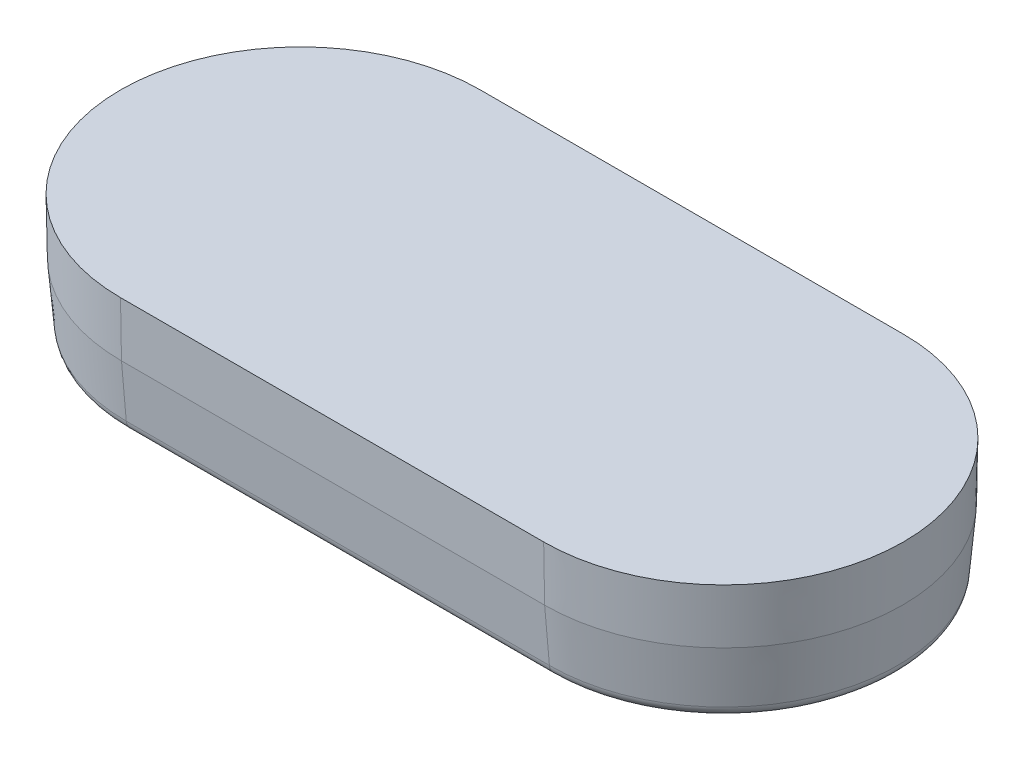
from build123d import *

# Parameters (mm, degrees)
BOSS_EXTRUDE1_DEPTH  = 6.35
BOSS_EXTRUDE1_DRAFT  = -1
CUT_EXTRUDE3_DEPTH   = 24.502539844
LPATTERN1_COUNT      = 12
LPATTERN1_PITCH      = 3.175
LPATTERN1_COUNT_DIR2 = 8
LPATTERN1_PITCH_DIR2 = 3.175
BOSS_EXTRUDE3_DEPTH  = 6.35
BOSS_EXTRUDE3_DRAFT  = -1
SKETCH8_OUTSIDE_W    = 56.55
SKETCH8_OUTSIDE_H    = 34.326
CUT_EXTRUDE4_DEPTH   = 24.502539844
CUT_EXTRUDE4_DRAFT   = 5
DRAFT2_ANGLE         = -5
FILLET2_R            = 0.635


with BuildPart() as part:
    # Sketch1 → Boss-Extrude1 (with draft: the straight prism first)
    with BuildSketch(Plane(origin=(0, 0, 0), x_dir=(1, 0, 0), z_dir=(0, 1, 0))):
        with BuildLine():
            ThreePointArc((-11.1125, 9.4488), (-20.5613, 0), (-11.1125, -9.4488))
            Line((-11.1125, -9.4488), (11.1125, -9.4488))
            ThreePointArc((11.1125, -9.4488), (20.5613, 0), (11.1125, 9.4488))
            Line((11.1125, 9.4488), (-11.1125, 9.4488))
        make_face()
    extrude(amount=-BOSS_EXTRUDE1_DEPTH)
    # Boss-Extrude1: the draft: its side faces are tilted about the plane it starts from
    boss_extrude1_sides = [part.faces().sort_by_distance(p)[0] for p in [
        (0, -3.175, -9.4488),
        (-20.5613, -3.175, 0),
        (0, -3.175, 9.4488),
        (20.5613, -3.175, 0),
    ]]
    draft(boss_extrude1_sides, Plane(origin=(0, 0, 0), x_dir=(1, 0, 0), z_dir=(0, 1, 0)), BOSS_EXTRUDE1_DRAFT)

    # Sketch6 → Cut-Extrude3 (cut, symmetric)
    with BuildSketch(Plane.XY):
        Polygon((0, -1.5875), (-7.9375, -9.525), (7.9375, -9.525), align=None)
    cut_extrude3 = extrude(amount=CUT_EXTRUDE3_DEPTH, both=True, mode=Mode.SUBTRACT)

    # LPattern1: Cut-Extrude3 12 × 8
    with Locations(*[Vector(1, 0, 0) * (i * LPATTERN1_PITCH) + Vector(-1, 0, 0) * (j * LPATTERN1_PITCH_DIR2) for i in range(LPATTERN1_COUNT) for j in range(LPATTERN1_COUNT_DIR2) if (i, j) != (0, 0)]):
        add(cut_extrude3, mode=Mode.SUBTRACT)


with BuildPart() as boss_extrude3_tool:
    # Sketch7 → Boss-Extrude3 (with draft: the straight prism first)
    with BuildSketch(Plane(origin=(0, 0, 0), x_dir=(1, 0, 0), z_dir=(0, 1, 0))):
        with BuildLine():
            Line((-11.1125, -9.4488), (11.1125, -9.4488))
            ThreePointArc((11.1125, -9.4488), (20.5613, 0), (11.1125, 9.4488))
            Line((11.1125, 9.4488), (-11.1125, 9.4488))
            ThreePointArc((-11.1125, 9.4488), (-20.5613, 0), (-11.1125, -9.4488))
        make_face()
        with BuildLine():
            Line((-11.1125, -7.2898), (11.1125, -7.2898))
            ThreePointArc((11.1125, -7.2898), (18.4023, 0), (11.1125, 7.2898))
            Line((11.1125, 7.2898), (-11.1125, 7.2898))
            ThreePointArc((-11.1125, 7.2898), (-18.4023, 0), (-11.1125, -7.2898))
        make_face(mode=Mode.SUBTRACT)
    extrude(amount=-BOSS_EXTRUDE3_DEPTH)
    # Boss-Extrude3: the draft: its side faces are tilted about the plane it starts from
    boss_extrude3_sides = [boss_extrude3_tool.faces().sort_by_distance(p)[0] for p in [
        (0, -3.175, 9.4488),
        (20.5613, -3.175, 0),
        (0, -3.175, -9.4488),
        (-20.5613, -3.175, 0),
        (18.4023, -3.175, 0),
        (0, -3.175, 7.2898),
        (-18.4023, -3.175, 0),
        (0, -3.175, -7.2898),
    ]]
    draft(boss_extrude3_sides, Plane(origin=(0, 0, 0), x_dir=(1, 0, 0), z_dir=(0, 1, 0)), BOSS_EXTRUDE3_DRAFT)


with BuildPart() as part_1:
    add(part.part)

    # Boss-Extrude3: add boss_extrude3_tool
    add(boss_extrude3_tool.part)


with BuildPart() as cut_extrude4_tool:
    # Sketch8 outside → Cut-Extrude4 (with draft: the straight prism first)
    with BuildSketch(Plane(origin=(0, 0, 0), x_dir=(1, 0, 0), z_dir=(0, 1, 0))):
        Rectangle(SKETCH8_OUTSIDE_W, SKETCH8_OUTSIDE_H)
        with BuildLine():
            Line((-11.1125, -9.652), (11.1125, -9.652))
            ThreePointArc((11.1125, -9.652), (20.7645, 0), (11.1125, 9.652))
            Line((11.1125, 9.652), (-11.1125, 9.652))
            ThreePointArc((-11.1125, 9.652), (-20.7645, 0), (-11.1125, -9.652))
        make_face(mode=Mode.SUBTRACT)
    extrude(amount=-CUT_EXTRUDE4_DEPTH)
    # Cut-Extrude4: the draft: its side faces are tilted about the plane it starts from
    cut_extrude4_sides = [cut_extrude4_tool.faces().sort_by_distance(p)[0] for p in [
        (0, -12.251269922, 17.163),
        (28.275, -12.251269922, 0),
        (0, -12.251269922, -17.163),
        (-28.275, -12.251269922, 0),
        (-20.7645, -12.251269922, 0),
        (0, -12.251269922, -9.652),
        (20.7645, -12.251269922, 0),
        (0, -12.251269922, 9.652),
    ]]
    draft(cut_extrude4_sides, Plane(origin=(0, 0, 0), x_dir=(1, 0, 0), z_dir=(0, 1, 0)), CUT_EXTRUDE4_DRAFT)


with BuildPart() as part_2:
    add(part_1.part)

    # Cut-Extrude4: cut by cut_extrude4_tool
    add(cut_extrude4_tool.part, mode=Mode.SUBTRACT)

    # Draft2
    draft2_faces = [part_2.faces().sort_by_distance(p)[0] for p in [
        (-18.471574789, -3.968749997, 0),
        (0, -4.339166667, -7.365540436),
        (18.471574789, -3.968749997, 0),
        (0, -4.339166667, 7.365540436),
    ]]
    draft(draft2_faces, Plane(origin=(-11.1125, 0, 0), x_dir=(0, 0, 1), z_dir=(0, 1, 0)), DRAFT2_ANGLE)

    # Fillet2
    fillet2_edges = [part_2.edges().sort_by_distance(p)[0] for p in [
        (0, -6.35, -7.845353013),
        (-18.957853013, -6.35, 0),
        (0, -6.35, 7.845353013),
        (18.957853013, -6.35, 0),
        (0, -6.35, -9.096446987),
        (-20.208946987, -6.35, 0),
        (0, -6.35, 9.096446987),
        (20.208946987, -6.35, 0),
    ]]
    fillet(fillet2_edges, radius=FILLET2_R)


solid = part_2.part
